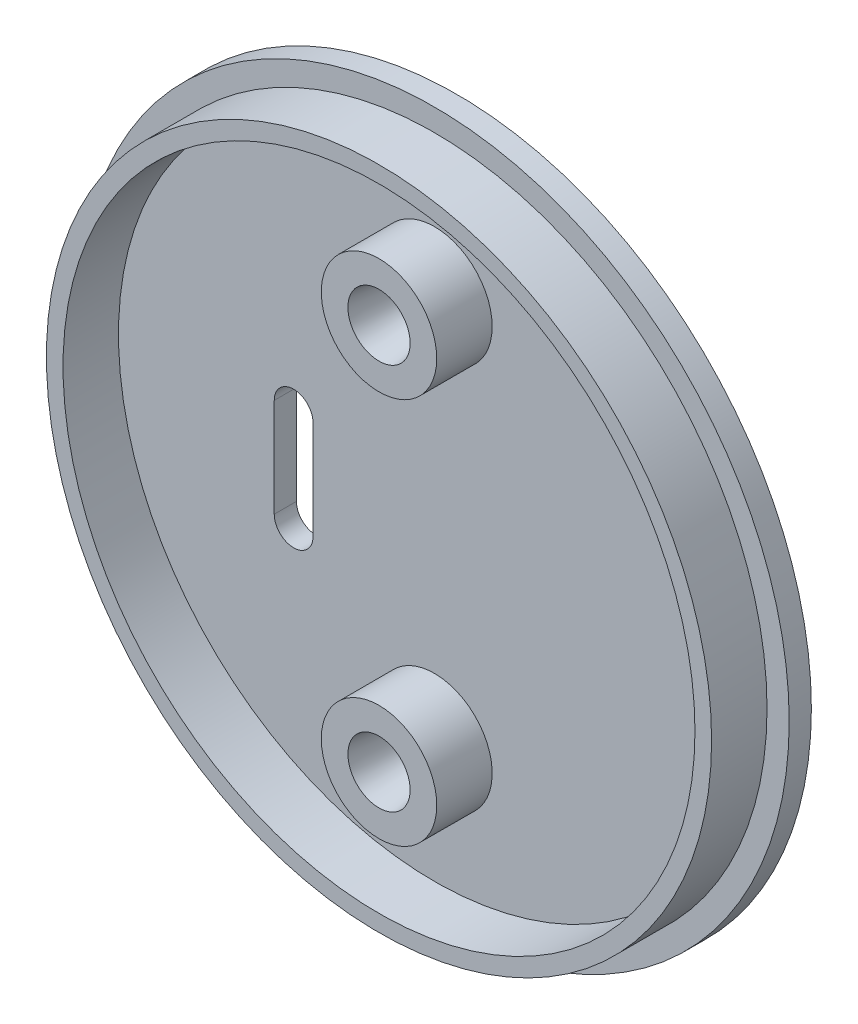
from build123d import *

# Parameters (mm, degrees)
SKETCH1_R               = 32
BOSS_EXTRUDE1_DEPTH     = 0.999998
SKETCH8_R               = 30
SKETCH8_R_2             = 28.5
BOSS_EXTRUDE4_DEPTH     = 5
SKETCH9_R               = 5.207
BOSS_EXTRUDE5_DEPTH     = 5
CUT_EXTRUDE1_DEPTH      = 1
CUT_EXTRUDE1_DEPTH_BACK = 7.999996
SKETCH10_R              = 2.8067
CUT_EXTRUDE2_DEPTH      = 4.7
CUT_EXTRUDE2_TAPER      = 8


with BuildPart() as part:
    # Sketch1 → Boss-Extrude1 (new body, symmetric)
    with BuildSketch(Plane.XY):
        Circle(SKETCH1_R)
    extrude(amount=BOSS_EXTRUDE1_DEPTH, both=True)

    # Sketch8 → Boss-Extrude4 (add)
    with BuildSketch(Plane.XY.offset(0.999998)):
        Circle(SKETCH8_R)
        Circle(SKETCH8_R_2, mode=Mode.SUBTRACT)
    extrude(amount=BOSS_EXTRUDE4_DEPTH)

    # Sketch9 → Boss-Extrude5 (add)
    with BuildSketch(Plane.XY.offset(0.999998)):
        with Locations((0, 17.4498)):
            Circle(SKETCH9_R)
        with Locations((0, -17.4498)):
            Circle(SKETCH9_R)
    extrude(amount=BOSS_EXTRUDE5_DEPTH)

    # Sketch7 → Cut-Extrude1 (cut, two sides)
    with BuildSketch(Plane(origin=(0, 0, -0.999998), x_dir=(-1, 0, 0), z_dir=(0, 0, -1))) as cut_extrude1_sk:
        with BuildLine():
            Line((14.45, 1.8542), (14.45, -7.0358))
            ThreePointArc((14.45, -7.0358), (12.7, -8.7858), (10.95, -7.0358))
            Line((10.95, -7.0358), (10.95, 1.8542))
            ThreePointArc((10.95, 1.8542), (12.7, 3.6042), (14.45, 1.8542))
        make_face()
    extrude(amount=CUT_EXTRUDE1_DEPTH, mode=Mode.SUBTRACT)
    extrude(cut_extrude1_sk.sketch, amount=-CUT_EXTRUDE1_DEPTH_BACK, mode=Mode.SUBTRACT)

    # Sketch10 → Cut-Extrude2 (cut)
    with BuildSketch(Plane.XY.offset(5.999998)):
        with Locations((0, 17.4498)):
            Circle(SKETCH10_R)
        with Locations((0, -17.4498)):
            Circle(SKETCH10_R)
    extrude(amount=-CUT_EXTRUDE2_DEPTH, taper=CUT_EXTRUDE2_TAPER, mode=Mode.SUBTRACT)


solid = part.part
